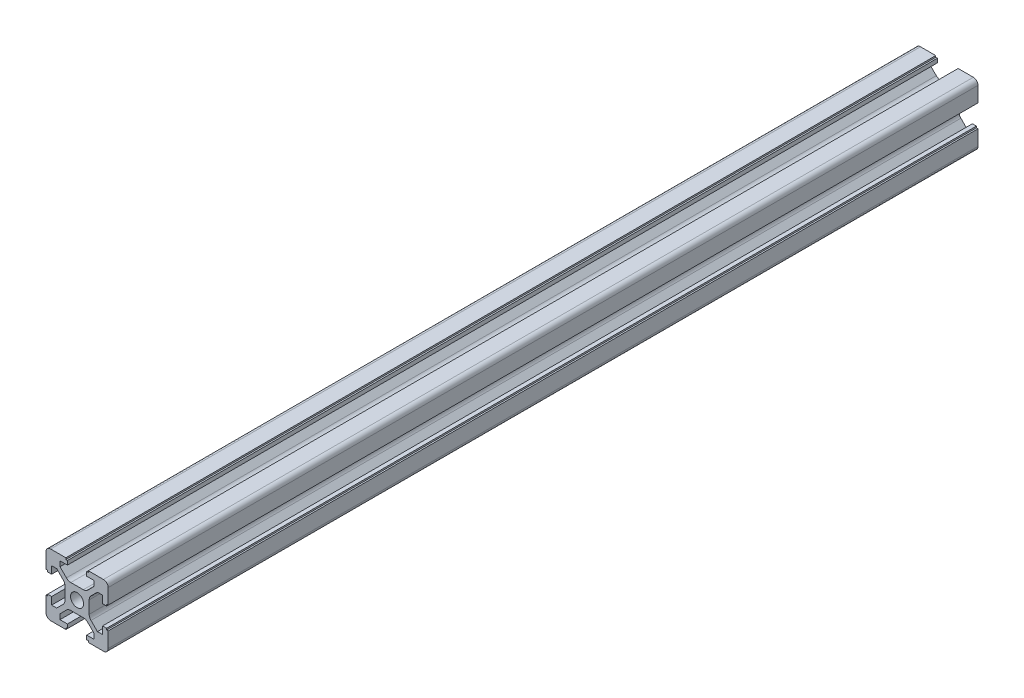
from build123d import *

# Parameters (mm, degrees)
SKETCH_1_R      = 2.1
EXTRUDE_1_DEPTH = 140


with BuildPart() as part:
    # 草图1 → 凸台-拉伸1 (new body, symmetric)
    with BuildSketch(Plane.XY):
        with BuildLine():
            Line((-3.425126266, 4.485786438), (-5.5, 6.560660172))
            Line((-5.5, 6.560660172), (-5.5, 8.2))
            Line((-5.5, 8.2), (-3.1, 8.2))
            Line((-3.1, 8.2), (-3.1, 9.5))
            Line((-3.1, 9.5), (-3.6, 9.5))
            Line((-3.6, 9.5), (-3.6, 10))
            Line((-3.6, 10), (-8.5, 10))
            ThreePointArc((-8.5, 10), (-9.560660172, 9.560660172), (-10, 8.5))
            Line((-10, 8.5), (-10, 3.6))
            Line((-10, 3.6), (-9.5, 3.6))
            Line((-9.5, 3.6), (-9.5, 3.1))
            Line((-9.5, 3.1), (-8.2, 3.1))
            Line((-8.2, 3.1), (-8.2, 5.5))
            Line((-8.2, 5.5), (-6.560660172, 5.5))
            Line((-6.560660172, 5.5), (-4.485786438, 3.425126266))
            ThreePointArc((-4.485786438, 3.425126266), (-4.052240935, 2.776279568), (-3.9, 2.010912703))
            Line((-3.9, 2.010912703), (-3.9, -2.010912703))
            ThreePointArc((-3.9, -2.010912703), (-4.052240935, -2.776279568), (-4.485786438, -3.425126266))
            Line((-4.485786438, -3.425126266), (-6.560660172, -5.5))
            Line((-6.560660172, -5.5), (-8.2, -5.5))
            Line((-8.2, -5.5), (-8.2, -3.1))
            Line((-8.2, -3.1), (-9.5, -3.1))
            Line((-9.5, -3.1), (-9.5, -3.6))
            Line((-9.5, -3.6), (-10, -3.6))
            Line((-10, -3.6), (-10, -8.5))
            ThreePointArc((-10, -8.5), (-9.560660172, -9.560660172), (-8.5, -10))
            Line((-8.5, -10), (-3.6, -10))
            Line((-3.6, -10), (-3.6, -9.5))
            Line((-3.6, -9.5), (-3.1, -9.5))
            Line((-3.1, -9.5), (-3.1, -8.2))
            Line((-3.1, -8.2), (-5.5, -8.2))
            Line((-5.5, -8.2), (-5.5, -6.560660172))
            Line((-5.5, -6.560660172), (-3.425126266, -4.485786438))
            ThreePointArc((-3.425126266, -4.485786438), (-2.776279568, -4.052240935), (-2.010912703, -3.9))
            Line((-2.010912703, -3.9), (2.010912703, -3.9))
            ThreePointArc((2.010912703, -3.9), (2.776279568, -4.052240935), (3.425126266, -4.485786438))
            Line((3.425126266, -4.485786438), (5.5, -6.560660172))
            Line((5.5, -6.560660172), (5.5, -8.2))
            Line((5.5, -8.2), (3.1, -8.2))
            Line((3.1, -8.2), (3.1, -9.5))
            Line((3.1, -9.5), (3.6, -9.5))
            Line((3.6, -9.5), (3.6, -10))
            Line((3.6, -10), (8.5, -10))
            ThreePointArc((8.5, -10), (9.560660172, -9.560660172), (10, -8.5))
            Line((10, -8.5), (10, -3.6))
            Line((10, -3.6), (9.5, -3.6))
            Line((9.5, -3.6), (9.5, -3.1))
            Line((9.5, -3.1), (8.2, -3.1))
            Line((8.2, -3.1), (8.2, -5.5))
            Line((8.2, -5.5), (6.560660172, -5.5))
            Line((6.560660172, -5.5), (4.485786438, -3.425126266))
            ThreePointArc((4.485786438, -3.425126266), (4.052240935, -2.776279568), (3.9, -2.010912703))
            Line((3.9, -2.010912703), (3.9, 2.010912703))
            ThreePointArc((3.9, 2.010912703), (4.052240935, 2.776279568), (4.485786438, 3.425126266))
            Line((4.485786438, 3.425126266), (6.560660172, 5.5))
            Line((6.560660172, 5.5), (8.2, 5.5))
            Line((8.2, 5.5), (8.2, 3.1))
            Line((8.2, 3.1), (9.5, 3.1))
            Line((9.5, 3.1), (9.5, 3.6))
            Line((9.5, 3.6), (10, 3.6))
            Line((10, 3.6), (10, 8.5))
            ThreePointArc((10, 8.5), (9.560660172, 9.560660172), (8.5, 10))
            Line((8.5, 10), (3.6, 10))
            Line((3.6, 10), (3.6, 9.5))
            Line((3.6, 9.5), (3.1, 9.5))
            Line((3.1, 9.5), (3.1, 8.2))
            Line((3.1, 8.2), (5.5, 8.2))
            Line((5.5, 8.2), (5.5, 6.560660172))
            Line((5.5, 6.560660172), (3.425126266, 4.485786438))
            ThreePointArc((3.425126266, 4.485786438), (2.776279568, 4.052240935), (2.010912703, 3.9))
            Line((2.010912703, 3.9), (-2.010912703, 3.9))
            ThreePointArc((-2.010912703, 3.9), (-2.776279568, 4.052240935), (-3.425126266, 4.485786438))
        make_face()
        Circle(SKETCH_1_R, mode=Mode.SUBTRACT)
    extrude(amount=EXTRUDE_1_DEPTH, both=True)


solid = part.part
